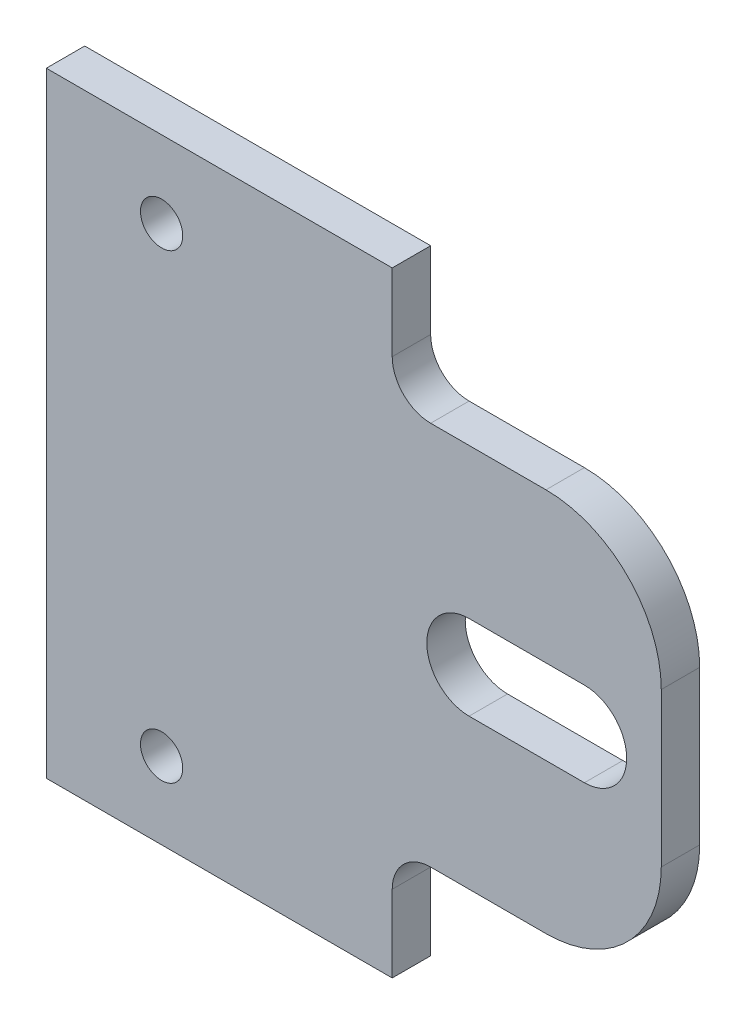
from build123d import *

# Parameters (mm, degrees)
ESQUISSE1_R        = 2.75
BOSS_EXTRU_1_DEPTH = 5
CONG_1_R           = 5
CONG_2_R           = 15


with BuildPart() as part:
    # Esquisse1 → Boss.-Extru.1 (new body)
    with BuildSketch(Plane.XY):
        Polygon((0, 80), (0, 0), (45, 0), (45, 15), (80, 15), (80, 65), (45, 65), (45, 80), align=None)
        with Locations((15, 10)):
            Circle(ESQUISSE1_R, mode=Mode.SUBTRACT)
        with Locations((15, 70)):
            Circle(ESQUISSE1_R, mode=Mode.SUBTRACT)
        with BuildLine():
            ThreePointArc((70, 45.5), (75.5, 40), (70, 34.5))
            Line((70, 34.5), (55, 34.5))
            ThreePointArc((55, 34.5), (49.5, 40), (55, 45.5))
            Line((55, 45.5), (70, 45.5))
        make_face(mode=Mode.SUBTRACT)
    extrude(amount=BOSS_EXTRU_1_DEPTH)

    # Congé1
    cong_1_edges = [part.edges().sort_by_distance(p)[0] for p in [
        (45, 65, 2.5),
        (45, 15, 2.5),
    ]]
    fillet(cong_1_edges, radius=CONG_1_R)

    # Congé2
    cong_2_edges = [part.edges().sort_by_distance(p)[0] for p in [
        (80, 65, 2.5),
        (80, 15, 2.5),
    ]]
    fillet(cong_2_edges, radius=CONG_2_R)


solid = part.part
